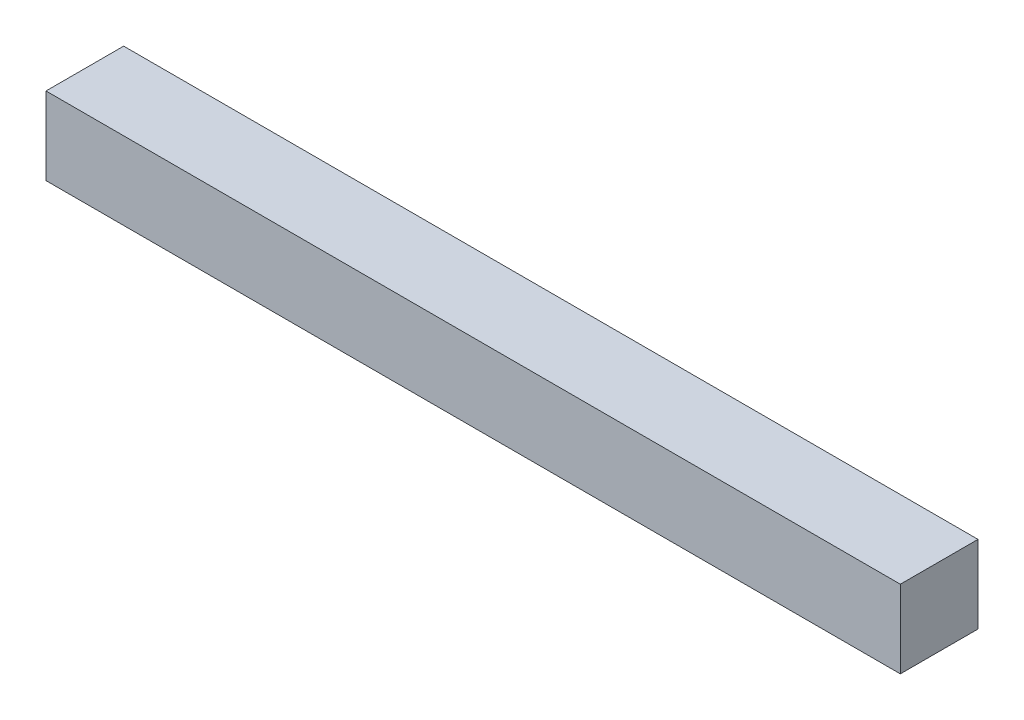
from build123d import *

# Parameters (mm, degrees)
SKETCH1_W           = 279.4
SKETCH1_H           = 25.4
BOSS_EXTRUDE1_DEPTH = 25.4


with BuildPart() as part:
    # Sketch1 → Boss-Extrude1 (new body)
    with BuildSketch(Plane(origin=(0, 0, 0), x_dir=(1, 0, 0), z_dir=(0, 1, 0))):
        Rectangle(SKETCH1_W, SKETCH1_H)
    extrude(amount=BOSS_EXTRUDE1_DEPTH)


solid = part.part
